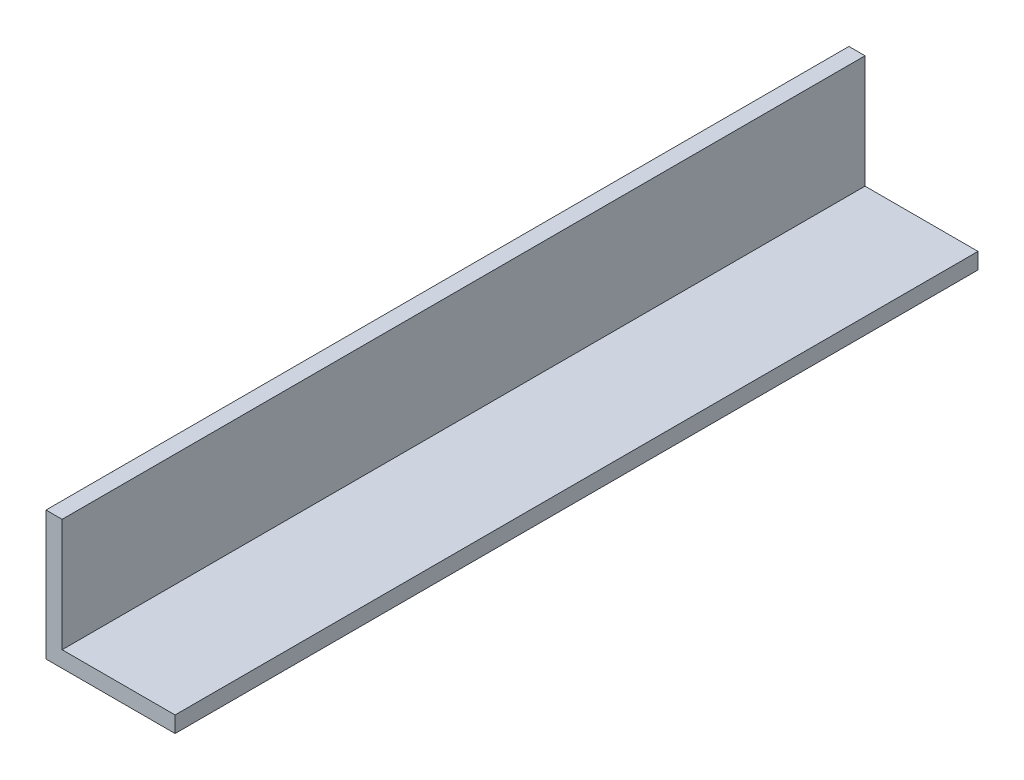
from build123d import *

# Parameters (mm, degrees)
BOSS_EXTRUDE1_DEPTH = 158


with BuildPart() as part:
    # Sketch1 → Boss-Extrude1 (new body)
    with BuildSketch(Plane.XY):
        Polygon((0, 0), (25.4, 0), (25.4, 3.175), (3.175, 3.175), (3.175, 25.4), (0, 25.4), align=None)
    extrude(amount=BOSS_EXTRUDE1_DEPTH)


solid = part.part
